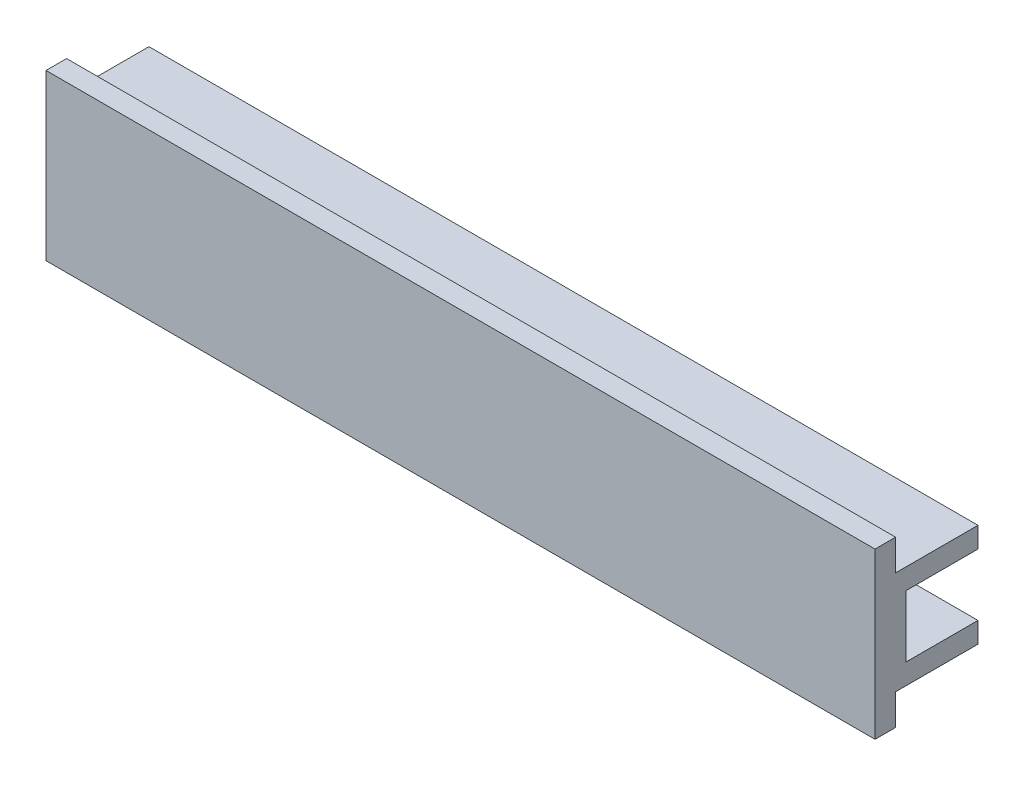
from build123d import *

# Parameters (mm, degrees)
EXTRUDE1_DEPTH = 40.25
SKETCH2_W      = 1
SKETCH2_H      = 6
EXTRUDE2_DEPTH = 22
EXTRUDE3_DEPTH = 1


with BuildPart() as part:
    # Sketch1 → Extrude1 (new body, symmetric)
    with BuildSketch(Plane(origin=(0, 0, 0), x_dir=(0, 0, -1), z_dir=(1, 0, 0))):
        Polygon((-3, 8), (-3, 5), (5, 5), (5, 3), (-2, 3), (-2, -3), (5, -3), (5, -5), (-3, -5), (-3, -8), (-5, -8), (-5, 8), align=None)
    extrude(amount=EXTRUDE1_DEPTH, both=True)

    # Sketch2 → Extrude2 (cut)
    with BuildSketch(Plane.ZY.offset(40.25)):
        with Locations((2.5, 0)):
            Rectangle(SKETCH2_W, SKETCH2_H)
    extrude(amount=-EXTRUDE2_DEPTH, mode=Mode.SUBTRACT)

    # Sketch3 → Extrude3 (cut)
    with BuildSketch(Plane(origin=(0, 0, 2), x_dir=(-1, 0, 0), z_dir=(0, 0, -1))):
        with BuildLine():
            Line((18.25, 3), (18.25, -3))
            ThreePointArc((18.25, -3), (15.25, 0), (18.25, 3))
        make_face()
    extrude(amount=-EXTRUDE3_DEPTH, mode=Mode.SUBTRACT)


solid = part.part
